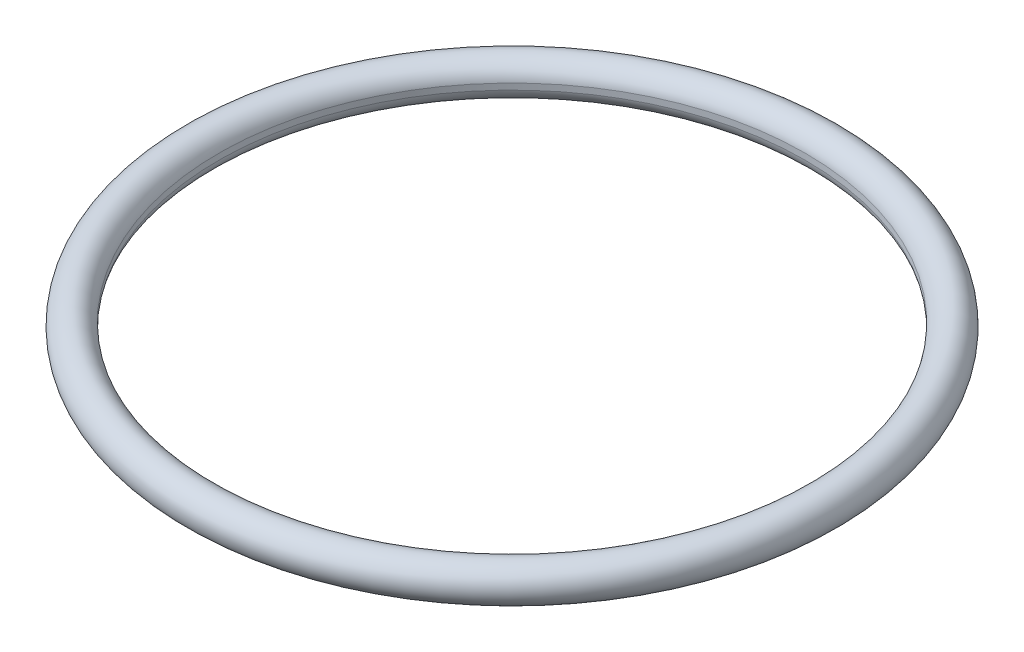
from build123d import *


with BuildPart() as part:
    # Sketch1 → Revolve1 (revolve)
    with BuildSketch(Plane.XY):
        with BuildLine():
            Line((-24.020980054, -0.25), (-24.020980054, 0.25))
            ThreePointArc((-24.020980054, 0.25), (-27, 0), (-24.020980054, -0.25))
        make_face()
    revolve(axis=Axis((0, 0, 0), (0, 1, 0)))


solid = part.part
